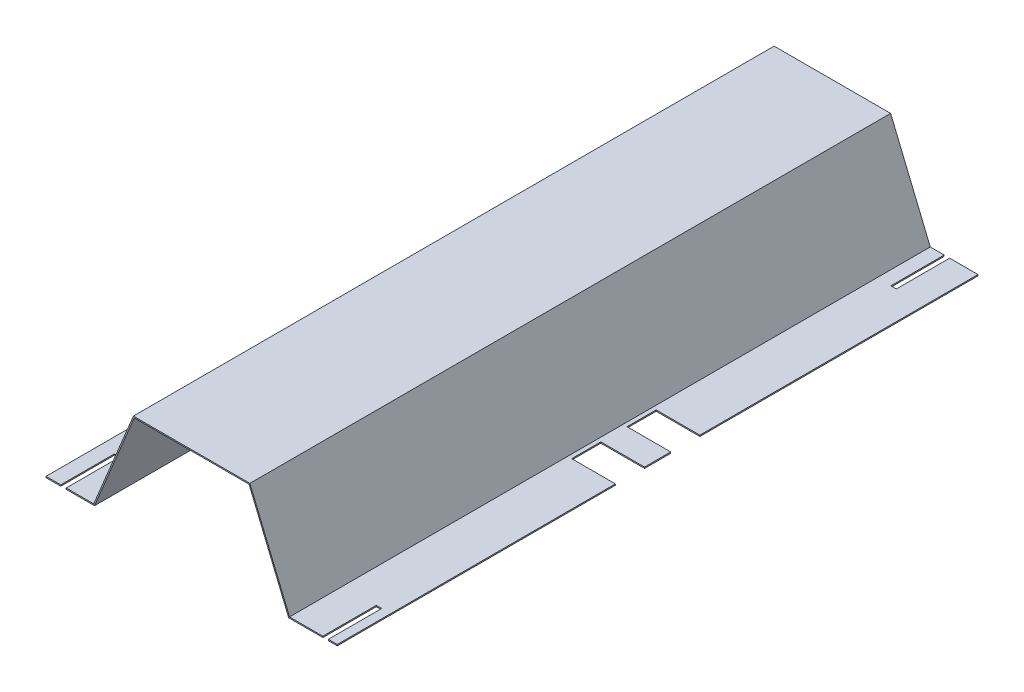
from build123d import *

# Parameters (mm, degrees)
BOSS_EXTRUDE1_DEPTH = 838.2
SKETCH4_W           = 57.15
SKETCH4_H           = 38.1
CUT_EXTRUDE3_DEPTH  = 2.54
SKETCH5_W           = 7.112
SKETCH5_H           = 69.85
CUT_EXTRUDE4_DEPTH  = 2.6002


with BuildPart() as part:
    # Sketch1 → Boss-Extrude1 (new body)
    with BuildSketch(Plane.XY):
        Polygon((-0.223728527, 63.622161409), (51.646062311, 189.021961409), (204.046062311, 189.021961409), (255.915853149, 63.622161409), (318.346062311, 63.622161409), (318.346062311, 62.021961409), (254.846062311, 62.021961409), (202.976271473, 187.421761409), (52.715853149, 187.421761409), (0.846062311, 62.021961409), (-62.653937689, 62.021961409), (-62.653937689, 63.622161409), align=None)
    extrude(amount=BOSS_EXTRUDE1_DEPTH)

    # Sketch4 → Cut-Extrude3 (cut)
    with BuildSketch(Plane(origin=(0, 63.622161409, 0), x_dir=(1, 0, 0), z_dir=(0, 1, 0))):
        with Locations((289.771062311, -382.905)):
            Rectangle(SKETCH4_W, SKETCH4_H)
        with Locations((289.771062311, -455.295)):
            Rectangle(SKETCH4_W, SKETCH4_H)
    extrude(amount=-CUT_EXTRUDE3_DEPTH, mode=Mode.SUBTRACT)

    # Sketch5 → Cut-Extrude4 (cut, through all)
    with BuildSketch(Plane(origin=(0, 63.622161409, 0), x_dir=(1, 0, 0), z_dir=(0, 1, 0))):
        with Locations((-27.093937689, -34.925)):
            Rectangle(SKETCH5_W, SKETCH5_H)
        with Locations((-39.793937689, -803.275)):
            Rectangle(SKETCH5_W, SKETCH5_H)
        with Locations((277.706062311, -34.925)):
            Rectangle(SKETCH5_W, SKETCH5_H)
        with Locations((303.106062311, -803.275)):
            Rectangle(SKETCH5_W, SKETCH5_H)
    extrude(amount=-CUT_EXTRUDE4_DEPTH, mode=Mode.SUBTRACT)


solid = part.part
